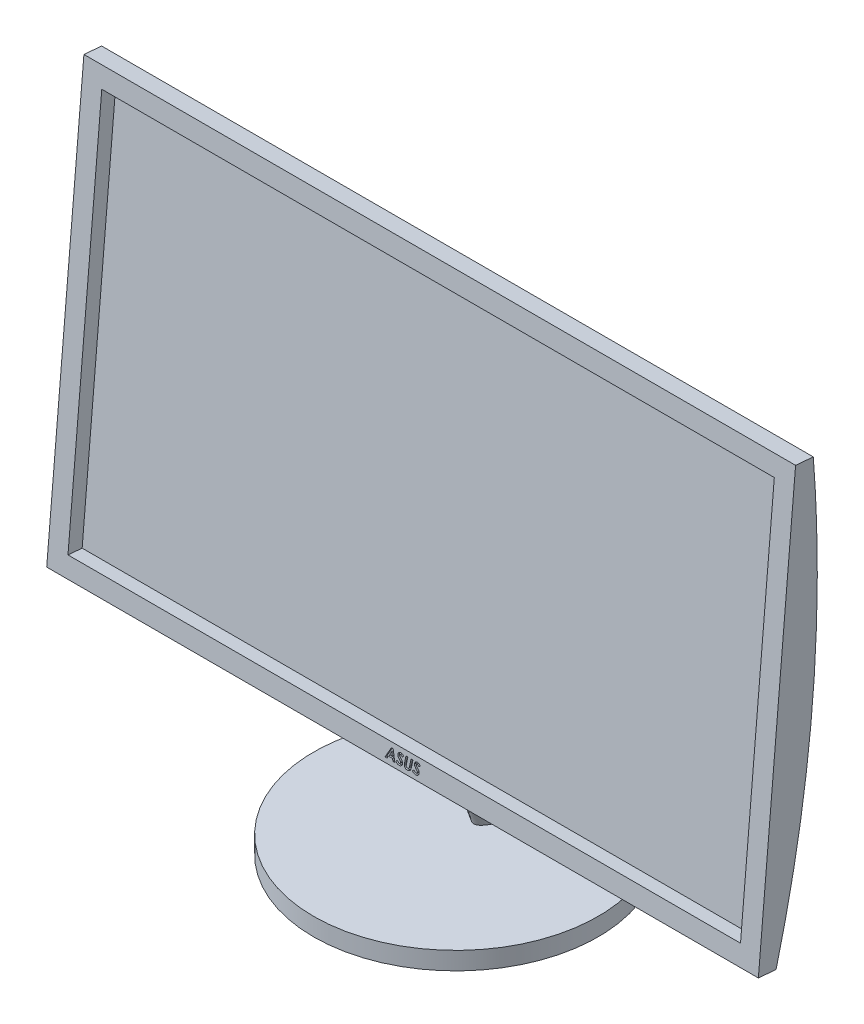
from build123d import *

# Parameters (mm, degrees)
SKETCH1_R           = 101.6
BOSS_EXTRUDE1_DEPTH = 12.7
BOSS_EXTRUDE2_DEPTH = 254
SKETCH3_W           = 480.06
SKETCH3_H           = 276.86
CUT_EXTRUDE1_DEPTH  = 10.16
BOSS_EXTRUDE3_DEPTH = 15.24
CUT_EXTRUDE2_DEPTH  = 1.27


with BuildPart() as part:
    # Sketch1 → Boss-Extrude1 (new body)
    with BuildSketch(Plane(origin=(0, 0, 0), x_dir=(1, 0, 0), z_dir=(0, 1, 0))):
        Circle(SKETCH1_R)
    extrude(amount=BOSS_EXTRUDE1_DEPTH)



with BuildPart() as body_2:
    # Sketch2 → Boss-Extrude2 (new body, symmetric)
    with BuildSketch(Plane(origin=(0, 0, 0), x_dir=(0, 0, -1), z_dir=(1, 0, 0))):
        with BuildLine():
            Line((-38.1, 69.85), (-11.534929611, 373.490143978))
            Line((-11.534929611, 373.490143978), (1.116743055, 372.383266045))
            add(Edge.make_bspline(
                [(1.116743055, 372.383266045), (13.137553192, 218.34943819), (-25.448327334, 68.743122067)],
                knots=[0, 0, 0, 1, 1, 1], degree=2))
            Line((-25.448327334, 68.743122067), (-38.1, 69.85))
        make_face()
    extrude(amount=BOSS_EXTRUDE2_DEPTH, both=True)

    # Sketch3 → Cut-Extrude1 (cut)
    with BuildSketch(Plane(origin=(0, 3.838587011, 43.8752503), x_dir=(1, 0, 0), z_dir=(0, 0.087155743, 0.996194698))):
        with Locations((0, 218.663565863)):
            Rectangle(SKETCH3_W, SKETCH3_H)
    extrude(amount=-CUT_EXTRUDE1_DEPTH, mode=Mode.SUBTRACT)

    # Sketch5 → Boss-Extrude3 (add)
    with BuildSketch(Plane(origin=(0, 1.624831145, 18.571904968), x_dir=(-1, 0, 0), z_dir=(0, -0.087155743, -0.996194698))):
        with BuildLine():
            add(Edge.make_bspline(
                [(-19.05, 104.363565863), (0, 129.763565863), (19.05, 104.363565863)],
                knots=[0, 0, 0, 1, 1, 1], degree=2))
            add(Edge.make_bspline(
                [(-19.05, 104.363565863), (0, 53.563565863), (19.05, 104.363565863)],
                knots=[0, 0, 0, 1, 1, 1], degree=2))
        make_face()
    extrude(amount=-BOSS_EXTRUDE3_DEPTH)


with BuildPart() as part_1:
    add(part.part)

    add(body_2.part)  # Loft1 merges body 2
    # Sketch4 → Loft1 section 0
    with BuildSketch(Plane(origin=(0, 12.7, 0), x_dir=(1, 0, 0), z_dir=(0, 1, 0))):
        with BuildLine():
            add(Edge.make_bspline(
                [(-19.94662191, 69.85), (0, 95.25), (19.94662191, 69.85)],
                knots=[0, 0, 0, 1, 1, 1], degree=2))
            add(Edge.make_bspline(
                [(-19.94662191, 69.85), (0, -44.45), (19.94662191, 69.85)],
                knots=[0, 0, 0, 1, 1, 1], degree=2))
        make_face()
    # Sketch5_2 → Loft1 section 1
    with BuildSketch(Plane(origin=(0, 1.624831145, 18.571904968), x_dir=(-1, 0, 0), z_dir=(0, -0.087155743, -0.996194698))):
        with BuildLine():
            add(Edge.make_bspline(
                [(-19.05, 104.363565863), (0, 129.763565863), (19.05, 104.363565863)],
                knots=[0, 0, 0, 1, 1, 1], degree=2))
            add(Edge.make_bspline(
                [(-19.05, 104.363565863), (0, 53.563565863), (19.05, 104.363565863)],
                knots=[0, 0, 0, 1, 1, 1], degree=2))
        make_face()
    loft()

    # Sketch6 → Cut-Extrude2 (cut)
    with BuildSketch(Plane(origin=(0, 3.838587011, 43.8752503), x_dir=(1, 0, 0), z_dir=(0, 0.087155743, 0.996194698))):
        Polygon((-8.813296274, 76.846899196), (-7.646839944, 76.846899196), (-5.766559829, 69.438565863), (-7.134845753, 69.438565863), (-7.544441106, 71.053202615), (-10.43238515, 71.053202615), (-11.299065171, 69.438565863), (-12.794978632, 69.438565863), align=None)
        Polygon((-7.860541867, 72.287924837), (-8.471966814, 74.699491678), (-9.767534722, 72.287924837), align=None, mode=Mode.SUBTRACT)
        with BuildLine():
            Line((0.022684629, 75.81697465), (-1.007239917, 74.919129765))
            add(Edge.make_bspline(
                [(-1.007239917, 74.919129765), (-1.058713103, 74.988662101), (-1.157360514, 75.121919542), (-1.313893713, 75.300653678), (-1.463858266, 75.455971488), (-1.614915862, 75.57983077), (-1.762154008, 75.67804401), (-1.906855771, 75.74918767), (-2.049834532, 75.794144882), (-2.145207264, 75.799523337), (-2.191504741, 75.802134239)],
                knots=[0, 0, 0, 0, 0.000259419, 0.000497171, 0.000712296, 0.000906303, 0.00108206, 0.00124202, 0.001389, 0.00152766, 0.00152766, 0.00152766, 0.00152766], degree=3))
            add(Edge.make_bspline(
                [(-2.191504741, 75.802134239), (-2.235236662, 75.800240953), (-2.319338975, 75.796599912), (-2.440062251, 75.765557758), (-2.54978394, 75.71562454), (-2.643984406, 75.643389985), (-2.722660521, 75.56010653), (-2.781078602, 75.466646954), (-2.815100537, 75.363633905), (-2.819816468, 75.292364175), (-2.822222222, 75.256007102)],
                knots=[0, 0, 0, 0, 0.000131008, 0.000251946, 0.000371455, 0.000490178, 0.000605686, 0.000713604, 0.000818257, 0.000927241, 0.000927241, 0.000927241, 0.000927241], degree=3))
            add(Edge.make_bspline(
                [(-2.822222222, 75.256007102), (-2.820031249, 75.220190268), (-2.815422971, 75.144856655), (-2.781660305, 75.030652041), (-2.730589806, 74.91032004), (-2.669162931, 74.805691208), (-2.600193782, 74.710684966), (-2.527918434, 74.617722071), (-2.433546017, 74.506573502), (-2.318710719, 74.375966697), (-2.184509617, 74.224799676), (-2.027461972, 74.055271937), (-1.850395491, 73.866270098), (-1.724628768, 73.73427377), (-1.658733974, 73.665115008)],
                knots=[0, 0, 0, 0, 0.000107355, 0.000225799, 0.0003548, 0.000499119, 0.000588482, 0.000706927, 0.000852287, 0.001025819, 0.001228677, 0.001458684, 0.001719064, 0.002005638, 0.002005638, 0.002005638, 0.002005638], degree=3))
            add(Edge.make_bspline(
                [(-1.658733974, 73.665115008), (-1.622987737, 73.6281373), (-1.554397653, 73.557184264), (-1.458156679, 73.453559677), (-1.372259631, 73.357519363), (-1.292951794, 73.272426995), (-1.22505921, 73.193888984), (-1.167091753, 73.123789573), (-1.117880882, 73.063115161), (-1.088786899, 73.025057637), (-1.075505809, 73.007684787)],
                knots=[0, 0, 0, 0, 0.00015429, 0.000296053, 0.000424232, 0.000540831, 0.000644978, 0.000735614, 0.00081372, 0.000879321, 0.000879321, 0.000879321, 0.000879321], degree=3))
            add(Edge.make_bspline(
                [(-1.075505809, 73.007684787), (-1.022619691, 72.934621968), (-0.920618133, 72.793705571), (-0.788314538, 72.579452637), (-0.678884699, 72.373024039), (-0.592894876, 72.171976716), (-0.528568803, 71.974111701), (-0.481979348, 71.776158283), (-0.452631691, 71.576469891), (-0.449376719, 71.442118819), (-0.44775641, 71.375239541)],
                knots=[0, 0, 0, 0, 0.000270511, 0.000521735, 0.000754734, 0.000970839, 0.001176865, 0.001378088, 0.001580408, 0.001780951, 0.001780951, 0.001780951, 0.001780951], degree=3))
            add(Edge.make_bspline(
                [(-0.44775641, 71.375239541), (-0.449772697, 71.301423605), (-0.453740758, 71.156153472), (-0.484488362, 70.943014888), (-0.532380128, 70.738649164), (-0.603794016, 70.544284095), (-0.691972735, 70.357804649), (-0.803890269, 70.181941505), (-0.932636998, 70.013719068), (-1.081267705, 69.857111523), (-1.243946399, 69.713894637), (-1.42108551, 69.589873588), (-1.608321398, 69.484162086), (-1.807557418, 69.397133116), (-2.018186445, 69.33094045), (-2.239832725, 69.283859778), (-2.472087097, 69.252607798), (-2.631170412, 69.249960426), (-2.712403178, 69.248608598)],
                knots=[0, 0, 0, 0, 0.000221366, 0.000435649, 0.000644778, 0.000849925, 0.001055694, 0.001262397, 0.001474038, 0.001690301, 0.001909065, 0.002123163, 0.002337796, 0.002553125, 0.002774187, 0.002998901, 0.003232306, 0.003475852, 0.003475852, 0.003475852, 0.003475852], degree=3))
            add(Edge.make_bspline(
                [(-2.712403178, 69.248608598), (-2.774765847, 69.249858157), (-2.898218545, 69.252331776), (-3.081198041, 69.268755366), (-3.259740939, 69.296792571), (-3.433584861, 69.337252339), (-3.603092796, 69.387772109), (-3.768529011, 69.448412429), (-3.929479562, 69.521810468), (-4.086150569, 69.606057655), (-4.238556518, 69.701483481), (-4.385782913, 69.809226186), (-4.529418231, 69.927208055), (-4.667579875, 70.057663567), (-4.803184921, 70.196991697), (-4.933858268, 70.348362002), (-5.058286881, 70.51240891), (-5.137274318, 70.626969878), (-5.177395499, 70.685160414)],
                knots=[0, 0, 0, 0, 0.000187083, 0.000370349, 0.000550652, 0.000728849, 0.000905393, 0.001081, 0.001257001, 0.001435611, 0.001614313, 0.001795979, 0.001982574, 0.002171566, 0.002365726, 0.002565648, 0.002771047, 0.002983078, 0.002983078, 0.002983078, 0.002983078], degree=3))
            Line((-5.177395499, 70.685160414), (-4.080689103, 71.547388312))
            add(Edge.make_bspline(
                [(-4.080689103, 71.547388312), (-4.026063783, 71.463394862), (-3.921295892, 71.302300764), (-3.750529063, 71.084852278), (-3.576432995, 70.900045319), (-3.398375547, 70.748598443), (-3.215783874, 70.630761119), (-3.029968679, 70.546530054), (-2.840102986, 70.492352763), (-2.711266346, 70.486330115), (-2.647105369, 70.48333082)],
                knots=[0, 0, 0, 0, 0.00030047, 0.000576282, 0.000828211, 0.001060978, 0.001275872, 0.001477789, 0.001671466, 0.001863603, 0.001863603, 0.001863603, 0.001863603], degree=3))
            add(Edge.make_bspline(
                [(-2.647105369, 70.48333082), (-2.587905806, 70.485925259), (-2.472662657, 70.490975825), (-2.307807871, 70.53800008), (-2.156559854, 70.610491014), (-2.025618511, 70.713996681), (-1.915309606, 70.835557174), (-1.835124884, 70.974040604), (-1.786851718, 71.12577318), (-1.780635778, 71.230937422), (-1.777457265, 71.284713032)],
                knots=[0, 0, 0, 0, 0.000177223, 0.000344999, 0.000510261, 0.000677386, 0.000842408, 0.000999975, 0.00115393, 0.001315035, 0.001315035, 0.001315035, 0.001315035], degree=3))
            add(Edge.make_bspline(
                [(-1.777457265, 71.284713032), (-1.778975719, 71.328421864), (-1.782064534, 71.417333688), (-1.814262488, 71.549758111), (-1.862049577, 71.684035877), (-1.919968932, 71.797520882), (-1.982438712, 71.897032302), (-2.048594824, 71.987146942), (-2.131838183, 72.092920447), (-2.234821919, 72.21187012), (-2.353336357, 72.3480117), (-2.491872019, 72.496560542), (-2.646002619, 72.662432565), (-2.756669745, 72.775921485), (-2.814802017, 72.835536015)],
                knots=[0, 0, 0, 0, 0.000130899, 0.000266272, 0.00040663, 0.000557951, 0.000647302, 0.000758922, 0.000893119, 0.001051028, 0.001230842, 0.001434594, 0.001660329, 0.001910116, 0.001910116, 0.001910116, 0.001910116], degree=3))
            add(Edge.make_bspline(
                [(-2.814802017, 72.835536015), (-2.876329131, 72.899171398), (-2.995270881, 73.022188769), (-3.163541605, 73.202223873), (-3.315113531, 73.369790792), (-3.449815033, 73.525065846), (-3.567757379, 73.668328159), (-3.670981384, 73.79849091), (-3.756362765, 73.91727114), (-3.804517336, 73.994338588), (-3.826918069, 74.030189127)],
                knots=[0, 0, 0, 0, 0.000265544, 0.000513339, 0.00073925, 0.000943358, 0.001129952, 0.001295906, 0.001441682, 0.001568479, 0.001568479, 0.001568479, 0.001568479], degree=3))
            add(Edge.make_bspline(
                [(-3.826918069, 74.030189127), (-3.876934637, 74.119523229), (-3.973975415, 74.29284681), (-4.074017262, 74.565641908), (-4.139210607, 74.834932309), (-4.147732996, 75.014744963), (-4.151923077, 75.103150866)],
                knots=[0, 0, 0, 0, 0.00030668, 0.000595012, 0.000868981, 0.001133956, 0.001133956, 0.001133956, 0.001133956], degree=3))
            add(Edge.make_bspline(
                [(-4.151923077, 75.103150866), (-4.150418558, 75.160107511), (-4.147425789, 75.273404918), (-4.125880162, 75.440616986), (-4.092890487, 75.604124798), (-4.040299506, 75.761448223), (-3.979646935, 75.916526648), (-3.900366495, 76.065285231), (-3.81129463, 76.211726054), (-3.739835022, 76.302442757), (-3.703742655, 76.348261376)],
                knots=[0, 0, 0, 0, 0.000170826, 0.000339805, 0.000505127, 0.00067033, 0.000836781, 0.00100405, 0.001175359, 0.00135018, 0.00135018, 0.00135018, 0.00135018], degree=3))
            add(Edge.make_bspline(
                [(-3.703742655, 76.348261376), (-3.656097604, 76.40348164), (-3.562124394, 76.512395902), (-3.3995329, 76.651619283), (-3.227140707, 76.77187661), (-3.041236978, 76.868419005), (-2.843959448, 76.945364416), (-2.633431863, 76.99757703), (-2.411267675, 77.03168731), (-2.258912778, 77.035109171), (-2.181116453, 77.036856461)],
                knots=[0, 0, 0, 0, 0.000218522, 0.000431005, 0.000640123, 0.000847894, 0.0010579, 0.001273862, 0.001497382, 0.001730608, 0.001730608, 0.001730608, 0.001730608], degree=3))
            add(Edge.make_bspline(
                [(-2.181116453, 77.036856461), (-2.073536042, 77.03310067), (-1.86131794, 77.025691822), (-1.549113619, 76.968106754), (-1.251601117, 76.870495144), (-0.965804968, 76.737873927), (-0.696365584, 76.56321945), (-0.43968451, 76.352094376), (-0.195903391, 76.102993857), (-0.051535586, 75.914090709), (0.022684629, 75.81697465)],
                knots=[0, 0, 0, 0, 0.000322614, 0.000636404, 0.000948494, 0.001259863, 0.001578905, 0.001908966, 0.002255285, 0.002621711, 0.002621711, 0.002621711, 0.002621711], degree=3))
        make_face()
        with BuildLine():
            Line((1.540858707, 76.846899196), (2.882431891, 76.846899196))
            Line((2.882431891, 76.846899196), (2.242810163, 72.264180179))
            add(Edge.make_bspline(
                [(2.242810163, 72.264180179), (2.236274966, 72.214725448), (2.223735091, 72.119830659), (2.207317659, 71.982805194), (2.193864444, 71.857153091), (2.183721833, 71.742803609), (2.175000116, 71.639904197), (2.166432722, 71.54850807), (2.164133067, 71.467754392), (2.16313587, 71.417781213), (2.162671942, 71.394532076)],
                knots=[0, 0, 0, 0, 0.000149653, 0.000287157, 0.000414006, 0.000528748, 0.000631533, 0.000723843, 0.000804036, 0.000873802, 0.000873802, 0.000873802, 0.000873802], degree=3))
            add(Edge.make_bspline(
                [(2.162671942, 71.394532076), (2.165505689, 71.326453466), (2.170925322, 71.196250907), (2.220368711, 71.012004329), (2.305345189, 70.852719823), (2.421971462, 70.717086282), (2.571981875, 70.610099532), (2.753572666, 70.536991473), (2.962672112, 70.489951611), (3.112174553, 70.485618644), (3.191112447, 70.48333082)],
                knots=[0, 0, 0, 0, 0.000203968, 0.000390095, 0.000566696, 0.000741347, 0.000922145, 0.001113701, 0.00132505, 0.001561479, 0.001561479, 0.001561479, 0.001561479], degree=3))
            add(Edge.make_bspline(
                [(3.191112447, 70.48333082), (3.256588601, 70.485538725), (3.384020451, 70.489835821), (3.568439142, 70.525391439), (3.74127366, 70.580121137), (3.845813919, 70.636500497), (3.897516026, 70.664383838)],
                knots=[0, 0, 0, 0, 0.000196253, 0.000381954, 0.000561694, 0.00073757, 0.00073757, 0.00073757, 0.00073757], degree=3))
            add(Edge.make_bspline(
                [(3.897516026, 70.664383838), (3.934077124, 70.689429245), (4.0088127, 70.740625269), (4.106368741, 70.842826258), (4.190247088, 70.967402625), (4.251084792, 71.088228486), (4.295272265, 71.202523684), (4.329347924, 71.309465226), (4.360670148, 71.43630779), (4.39577408, 71.581346608), (4.427095609, 71.746019322), (4.460729392, 71.929319382), (4.490596581, 72.132533401), (4.511419386, 72.274569847), (4.522297342, 72.348770524)],
                knots=[0, 0, 0, 0, 0.000132679, 0.000271212, 0.000420637, 0.000581913, 0.000675889, 0.00078806, 0.00091836, 0.001067748, 0.00123568, 0.001421114, 0.001626803, 0.00185179, 0.00185179, 0.00185179, 0.00185179], degree=3))
            Line((4.522297342, 72.348770524), (5.150046741, 76.846899196))
            Line((5.150046741, 76.846899196), (6.491619925, 76.846899196))
            Line((6.491619925, 76.846899196), (5.872774773, 72.415552375))
            add(Edge.make_bspline(
                [(5.872774773, 72.415552375), (5.857524805, 72.306140074), (5.828005038, 72.094347785), (5.775911527, 71.789622534), (5.721336489, 71.508983959), (5.663902725, 71.252354725), (5.601513448, 71.019828649), (5.537521831, 70.810212364), (5.467521072, 70.625578834), (5.394313969, 70.462125362), (5.313908603, 70.315888154), (5.22784231, 70.180077431), (5.133257824, 70.053363827), (5.027436396, 69.937777923), (4.917511783, 69.826922071), (4.796230937, 69.728014193), (4.668242061, 69.636551665), (4.531364598, 69.555472104), (4.387122505, 69.481790366), (4.233719283, 69.420306805), (4.073837269, 69.366544245), (3.905619089, 69.323505963), (3.730232114, 69.289417161), (3.546768143, 69.266360679), (3.356118323, 69.250576477), (3.226268656, 69.249273895), (3.159947583, 69.248608598)],
                knots=[0, 0, 0, 0, 0.000331393, 0.000641487, 0.000927295, 0.00118903, 0.001430217, 0.001649418, 0.001846215, 0.002022216, 0.002186255, 0.002346401, 0.002504303, 0.002659837, 0.002816198, 0.002972198, 0.003128672, 0.003287741, 0.003449018, 0.003614093, 0.00378304, 0.003954734, 0.004134603, 0.004318678, 0.004509214, 0.004708125, 0.004708125, 0.004708125, 0.004708125], degree=3))
            add(Edge.make_bspline(
                [(3.159947583, 69.248608598), (3.071311459, 69.250051626), (2.899002788, 69.252856873), (2.647991514, 69.282302091), (2.411945319, 69.32715814), (2.190520638, 69.391678083), (1.983328507, 69.472229485), (1.792262806, 69.574342658), (1.615558887, 69.693467921), (1.455130599, 69.831459662), (1.313419234, 69.9865623), (1.186442153, 70.152976878), (1.083138228, 70.336094683), (0.996662927, 70.530756477), (0.929215513, 70.739129122), (0.88307026, 70.96107565), (0.851732824, 71.196264723), (0.849139392, 71.357818384), (0.847811498, 71.440537351)],
                knots=[0, 0, 0, 0, 0.000265793, 0.000516701, 0.000757106, 0.000985827, 0.00120767, 0.001422769, 0.001634337, 0.001845848, 0.002055891, 0.002263657, 0.002472396, 0.002685007, 0.00290183, 0.003127994, 0.003364344, 0.003612338, 0.003612338, 0.003612338, 0.003612338], degree=3))
            add(Edge.make_bspline(
                [(0.847811498, 71.440537351), (0.848013405, 71.479624978), (0.848440435, 71.562294718), (0.85530375, 71.692385659), (0.863840194, 71.835913672), (0.877289332, 71.992271228), (0.89563088, 72.16185485), (0.916447419, 72.344389603), (0.939776593, 72.540408521), (0.95839487, 72.675288696), (0.96801883, 72.745009506)],
                knots=[0, 0, 0, 0, 0.000117249, 0.000247979, 0.000390725, 0.000548599, 0.000718715, 0.00090243, 0.001099758, 0.001310899, 0.001310899, 0.001310899, 0.001310899], degree=3))
            Line((0.96801883, 72.745009506), (1.540858707, 76.846899196))
        make_face()
        with BuildLine():
            Line((11.895013689, 75.81697465), (10.865089143, 74.919129765))
            add(Edge.make_bspline(
                [(10.865089143, 74.919129765), (10.813615957, 74.988662101), (10.714968546, 75.121919542), (10.558435346, 75.300653678), (10.408470794, 75.455971488), (10.257413198, 75.57983077), (10.110175051, 75.67804401), (9.965473289, 75.74918767), (9.822494528, 75.794144882), (9.727121796, 75.799523337), (9.680824319, 75.802134239)],
                knots=[0, 0, 0, 0, 0.000259419, 0.000497171, 0.000712296, 0.000906303, 0.00108206, 0.00124202, 0.001389, 0.00152766, 0.00152766, 0.00152766, 0.00152766], degree=3))
            add(Edge.make_bspline(
                [(9.680824319, 75.802134239), (9.637092398, 75.800240953), (9.552990085, 75.796599912), (9.432266809, 75.765557758), (9.32254512, 75.71562454), (9.228344654, 75.643389985), (9.149668539, 75.56010653), (9.091250457, 75.466646954), (9.057228523, 75.363633905), (9.052512592, 75.292364175), (9.050106838, 75.256007102)],
                knots=[0, 0, 0, 0, 0.000131008, 0.000251946, 0.000371455, 0.000490178, 0.000605686, 0.000713604, 0.000818257, 0.000927241, 0.000927241, 0.000927241, 0.000927241], degree=3))
            add(Edge.make_bspline(
                [(9.050106838, 75.256007102), (9.052297811, 75.220190268), (9.056906089, 75.144856655), (9.090668755, 75.030652041), (9.141739254, 74.91032004), (9.203166129, 74.805691208), (9.272135278, 74.710684966), (9.344410626, 74.617722071), (9.438783043, 74.506573502), (9.553618341, 74.375966697), (9.687819443, 74.224799676), (9.844867088, 74.055271937), (10.021933569, 73.866270098), (10.147700292, 73.73427377), (10.213595085, 73.665115008)],
                knots=[0, 0, 0, 0, 0.000107355, 0.000225799, 0.0003548, 0.000499119, 0.000588482, 0.000706927, 0.000852287, 0.001025819, 0.001228677, 0.001458684, 0.001719064, 0.002005638, 0.002005638, 0.002005638, 0.002005638], degree=3))
            add(Edge.make_bspline(
                [(10.213595085, 73.665115008), (10.249341323, 73.6281373), (10.317931407, 73.557184264), (10.414172381, 73.453559677), (10.500069429, 73.357519363), (10.579377266, 73.272426995), (10.64726985, 73.193888984), (10.705237307, 73.123789573), (10.754448178, 73.063115161), (10.783542161, 73.025057637), (10.796823251, 73.007684787)],
                knots=[0, 0, 0, 0, 0.00015429, 0.000296053, 0.000424232, 0.000540831, 0.000644978, 0.000735614, 0.00081372, 0.000879321, 0.000879321, 0.000879321, 0.000879321], degree=3))
            add(Edge.make_bspline(
                [(10.796823251, 73.007684787), (10.849709369, 72.934621968), (10.951710926, 72.793705571), (11.084014521, 72.579452637), (11.193444361, 72.373024039), (11.279434184, 72.171976716), (11.343760256, 71.974111701), (11.390349712, 71.776158283), (11.419697369, 71.576469891), (11.422952341, 71.442118819), (11.42457265, 71.375239541)],
                knots=[0, 0, 0, 0, 0.000270511, 0.000521735, 0.000754734, 0.000970839, 0.001176865, 0.001378088, 0.001580408, 0.001780951, 0.001780951, 0.001780951, 0.001780951], degree=3))
            add(Edge.make_bspline(
                [(11.42457265, 71.375239541), (11.422556363, 71.301423605), (11.418588302, 71.156153472), (11.387840698, 70.943014888), (11.339948932, 70.738649164), (11.268535043, 70.544284095), (11.180356325, 70.357804649), (11.06843879, 70.181941505), (10.939692062, 70.013719068), (10.791061355, 69.857111523), (10.628382661, 69.713894637), (10.45124355, 69.589873588), (10.264007662, 69.484162086), (10.064771642, 69.397133116), (9.854142615, 69.33094045), (9.632496335, 69.283859778), (9.400241963, 69.252607798), (9.241158648, 69.249960426), (9.159925881, 69.248608598)],
                knots=[0, 0, 0, 0, 0.000221366, 0.000435649, 0.000644778, 0.000849925, 0.001055694, 0.001262397, 0.001474038, 0.001690301, 0.001909065, 0.002123163, 0.002337796, 0.002553125, 0.002774187, 0.002998901, 0.003232306, 0.003475852, 0.003475852, 0.003475852, 0.003475852], degree=3))
            add(Edge.make_bspline(
                [(9.159925881, 69.248608598), (9.097563213, 69.249858157), (8.974110514, 69.252331776), (8.791131018, 69.268755366), (8.612588121, 69.296792571), (8.438744199, 69.337252339), (8.269236264, 69.387772109), (8.103800048, 69.448412429), (7.942849498, 69.521810468), (7.78617849, 69.606057655), (7.633772542, 69.701483481), (7.486546147, 69.809226186), (7.342910829, 69.927208055), (7.204749185, 70.057663567), (7.069144139, 70.196991697), (6.938470792, 70.348362002), (6.814042179, 70.51240891), (6.735054742, 70.626969878), (6.69493356, 70.685160414)],
                knots=[0, 0, 0, 0, 0.000187083, 0.000370349, 0.000550652, 0.000728849, 0.000905393, 0.001081, 0.001257001, 0.001435611, 0.001614313, 0.001795979, 0.001982574, 0.002171566, 0.002365726, 0.002565648, 0.002771047, 0.002983078, 0.002983078, 0.002983078, 0.002983078], degree=3))
            Line((6.69493356, 70.685160414), (7.791639957, 71.547388312))
            add(Edge.make_bspline(
                [(7.791639957, 71.547388312), (7.846265277, 71.463394862), (7.951033168, 71.302300764), (8.121799996, 71.084852278), (8.295896065, 70.900045319), (8.473953513, 70.748598443), (8.656545185, 70.630761119), (8.842360381, 70.546530054), (9.032226074, 70.492352763), (9.161062713, 70.486330115), (9.225223691, 70.48333082)],
                knots=[0, 0, 0, 0, 0.00030047, 0.000576282, 0.000828211, 0.001060978, 0.001275872, 0.001477789, 0.001671466, 0.001863603, 0.001863603, 0.001863603, 0.001863603], degree=3))
            add(Edge.make_bspline(
                [(9.225223691, 70.48333082), (9.284423253, 70.485925259), (9.399666403, 70.490975825), (9.564521189, 70.53800008), (9.715769206, 70.610491014), (9.846710549, 70.713996681), (9.957019454, 70.835557174), (10.037204176, 70.974040604), (10.085477342, 71.12577318), (10.091693281, 71.230937422), (10.094871795, 71.284713032)],
                knots=[0, 0, 0, 0, 0.000177223, 0.000344999, 0.000510261, 0.000677386, 0.000842408, 0.000999975, 0.00115393, 0.001315035, 0.001315035, 0.001315035, 0.001315035], degree=3))
            add(Edge.make_bspline(
                [(10.094871795, 71.284713032), (10.093353341, 71.328421864), (10.090264526, 71.417333688), (10.058066572, 71.549758111), (10.010279483, 71.684035877), (9.952360128, 71.797520882), (9.889890348, 71.897032302), (9.823734236, 71.987146942), (9.740490877, 72.092920447), (9.637507141, 72.21187012), (9.518992703, 72.3480117), (9.380457041, 72.496560542), (9.226326441, 72.662432565), (9.115659315, 72.775921485), (9.057527043, 72.835536015)],
                knots=[0, 0, 0, 0, 0.000130899, 0.000266272, 0.00040663, 0.000557951, 0.000647302, 0.000758922, 0.000893119, 0.001051028, 0.001230842, 0.001434594, 0.001660329, 0.001910116, 0.001910116, 0.001910116, 0.001910116], degree=3))
            add(Edge.make_bspline(
                [(9.057527043, 72.835536015), (8.995999929, 72.899171398), (8.877058179, 73.022188769), (8.708787455, 73.202223873), (8.557215529, 73.369790792), (8.422514027, 73.525065846), (8.304571681, 73.668328159), (8.201347676, 73.79849091), (8.115966295, 73.91727114), (8.067811724, 73.994338588), (8.045410991, 74.030189127)],
                knots=[0, 0, 0, 0, 0.000265544, 0.000513339, 0.00073925, 0.000943358, 0.001129952, 0.001295906, 0.001441682, 0.001568479, 0.001568479, 0.001568479, 0.001568479], degree=3))
            add(Edge.make_bspline(
                [(8.045410991, 74.030189127), (7.995394423, 74.119523229), (7.898353645, 74.29284681), (7.798311798, 74.565641908), (7.733118453, 74.834932309), (7.724596063, 75.014744963), (7.720405983, 75.103150866)],
                knots=[0, 0, 0, 0, 0.00030668, 0.000595012, 0.000868981, 0.001133956, 0.001133956, 0.001133956, 0.001133956], degree=3))
            add(Edge.make_bspline(
                [(7.720405983, 75.103150866), (7.721910502, 75.160107511), (7.724903271, 75.273404918), (7.746448898, 75.440616986), (7.779438573, 75.604124798), (7.832029554, 75.761448223), (7.892682125, 75.916526648), (7.971962565, 76.065285231), (8.06103443, 76.211726054), (8.132494038, 76.302442757), (8.168586405, 76.348261376)],
                knots=[0, 0, 0, 0, 0.000170826, 0.000339805, 0.000505127, 0.00067033, 0.000836781, 0.00100405, 0.001175359, 0.00135018, 0.00135018, 0.00135018, 0.00135018], degree=3))
            add(Edge.make_bspline(
                [(8.168586405, 76.348261376), (8.216231455, 76.40348164), (8.310204666, 76.512395902), (8.47279616, 76.651619283), (8.645188353, 76.77187661), (8.831092082, 76.868419005), (9.028369612, 76.945364416), (9.238897197, 76.99757703), (9.461061385, 77.03168731), (9.613416282, 77.035109171), (9.691212607, 77.036856461)],
                knots=[0, 0, 0, 0, 0.000218522, 0.000431005, 0.000640123, 0.000847894, 0.0010579, 0.001273862, 0.001497382, 0.001730608, 0.001730608, 0.001730608, 0.001730608], degree=3))
            add(Edge.make_bspline(
                [(9.691212607, 77.036856461), (9.798793017, 77.03310067), (10.01101112, 77.025691822), (10.323215441, 76.968106754), (10.620727943, 76.870495144), (10.906524091, 76.737873927), (11.175963476, 76.56321945), (11.432644549, 76.352094376), (11.676425669, 76.102993857), (11.820793474, 75.914090709), (11.895013689, 75.81697465)],
                knots=[0, 0, 0, 0, 0.000322614, 0.000636404, 0.000948494, 0.001259863, 0.001578905, 0.001908966, 0.002255285, 0.002621711, 0.002621711, 0.002621711, 0.002621711], degree=3))
        make_face()
    extrude(amount=-CUT_EXTRUDE2_DEPTH, mode=Mode.SUBTRACT)


solid = part_1.part
